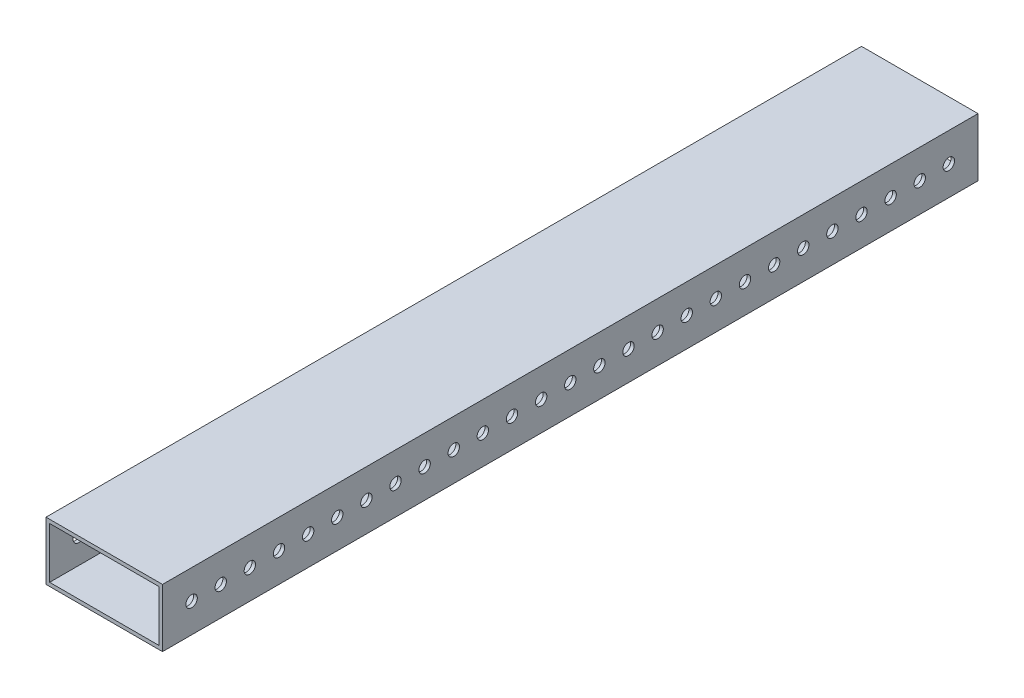
from build123d import *

# Parameters (mm, degrees)
SKETCH1_W           = 50.8
SKETCH1_H           = 25.4
SKETCH1_W_2         = 47.625
SKETCH1_H_2         = 22.225
BOSS_EXTRUDE1_DEPTH = 355.6
SKETCH2_R           = 2.4892
CUT_EXTRUDE1_DEPTH  = 51.8


with BuildPart() as part:
    # Sketch1 → Boss-Extrude1 (new body)
    with BuildSketch(Plane.XY):
        with Locations((25.4, 12.7)):
            Rectangle(SKETCH1_W, SKETCH1_H)
        with Locations((25.4, 12.7)):
            Rectangle(SKETCH1_W_2, SKETCH1_H_2, mode=Mode.SUBTRACT)
    extrude(amount=BOSS_EXTRUDE1_DEPTH)

    # Sketch2 → Cut-Extrude1 (cut, through all)
    with BuildSketch(Plane(origin=(50.8, 0, 0), x_dir=(0, 0, -1), z_dir=(1, 0, 0))):
        with Locations((-342.9, 12.7)):
            Circle(SKETCH2_R)
        with Locations((-330.2, 12.7)):
            Circle(SKETCH2_R)
        with Locations((-317.5, 12.7)):
            Circle(SKETCH2_R)
        with Locations((-304.8, 12.7)):
            Circle(SKETCH2_R)
        with Locations((-292.1, 12.7)):
            Circle(SKETCH2_R)
        with Locations((-279.4, 12.7)):
            Circle(SKETCH2_R)
        with Locations((-266.7, 12.7)):
            Circle(SKETCH2_R)
        with Locations((-254, 12.7)):
            Circle(SKETCH2_R)
        with Locations((-241.3, 12.7)):
            Circle(SKETCH2_R)
        with Locations((-228.6, 12.7)):
            Circle(SKETCH2_R)
        with Locations((-215.9, 12.7)):
            Circle(SKETCH2_R)
        with Locations((-203.2, 12.7)):
            Circle(SKETCH2_R)
        with Locations((-190.5, 12.7)):
            Circle(SKETCH2_R)
        with Locations((-177.8, 12.7)):
            Circle(SKETCH2_R)
        with Locations((-165.1, 12.7)):
            Circle(SKETCH2_R)
        with Locations((-152.4, 12.7)):
            Circle(SKETCH2_R)
        with Locations((-139.7, 12.7)):
            Circle(SKETCH2_R)
        with Locations((-127, 12.7)):
            Circle(SKETCH2_R)
        with Locations((-114.3, 12.7)):
            Circle(SKETCH2_R)
        with Locations((-101.6, 12.7)):
            Circle(SKETCH2_R)
        with Locations((-88.9, 12.7)):
            Circle(SKETCH2_R)
        with Locations((-76.2, 12.7)):
            Circle(SKETCH2_R)
        with Locations((-63.5, 12.7)):
            Circle(SKETCH2_R)
        with Locations((-50.8, 12.7)):
            Circle(SKETCH2_R)
        with Locations((-38.1, 12.7)):
            Circle(SKETCH2_R)
        with Locations((-25.4, 12.7)):
            Circle(SKETCH2_R)
        with Locations((-12.7, 12.7)):
            Circle(SKETCH2_R)
    extrude(amount=-CUT_EXTRUDE1_DEPTH, mode=Mode.SUBTRACT)


solid = part.part
